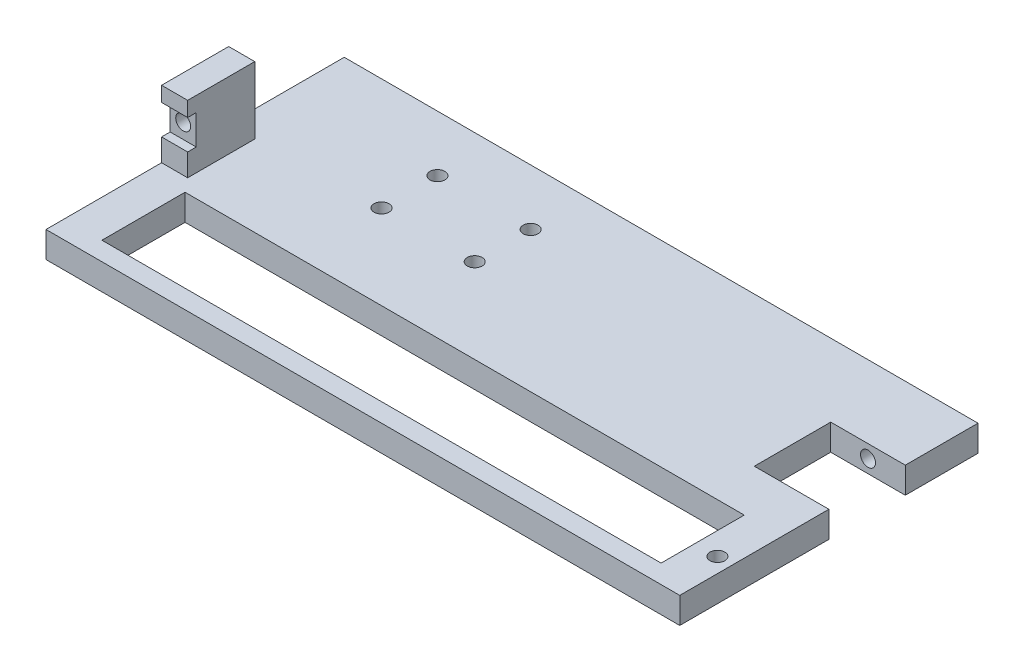
from build123d import *

# Parameters (mm, degrees)
SKETCH1_W           = 170
SKETCH1_H           = 80
BOSS_EXTRUDE1_DEPTH = 7
SKETCH2_W           = 7
SKETCH2_H           = 18
BOSS_EXTRUDE2_DEPTH = 18
SKETCH3_R           = 2
CUT_EXTRUDE1_DEPTH  = 20
SKETCH4_W           = 7
SKETCH4_H           = 8
CUT_EXTRUDE2_DEPTH  = 2.3
SKETCH5_W           = 150
SKETCH5_H           = 22.295371368
CUT_EXTRUDE3_DEPTH  = 11
SKETCH6_R           = 2
SKETCH6_W           = 20
SKETCH6_H           = 20.5
CUT_EXTRUDE4_DEPTH  = 11
SKETCH7_R           = 2
CUT_EXTRUDE5_DEPTH  = 25
CUT_EXTRUDE6_START  = 25
SKETCH7_2_R         = 2
CUT_EXTRUDE6_DEPTH  = 25
SKETCH10_R          = 2
CUT_EXTRUDE7_DEPTH  = 10


with BuildPart() as part:
    # Sketch1 → Boss-Extrude1 (new body)
    with BuildSketch(Plane(origin=(0, 0, 0), x_dir=(1, 0, 0), z_dir=(0, 1, 0))):
        with Locations((5.170316302, -0.291970803)):
            Rectangle(SKETCH1_W, SKETCH1_H)
    extrude(amount=BOSS_EXTRUDE1_DEPTH)

    # Sketch2 → Boss-Extrude2 (add)
    with BuildSketch(Plane(origin=(0, 7, 0), x_dir=(1, 0, 0), z_dir=(0, 1, 0))):
        with Locations((-76.329683698, -0.291970803)):
            Rectangle(SKETCH2_W, SKETCH2_H)
    extrude(amount=BOSS_EXTRUDE2_DEPTH)

    # Sketch3 → Cut-Extrude1 (cut)
    with BuildSketch(Plane(origin=(0, 0, -8.708029197), x_dir=(-1, 0, 0), z_dir=(0, 0, -1))):
        with Locations((76.329683698, 17)):
            Circle(SKETCH3_R)
    extrude(amount=-CUT_EXTRUDE1_DEPTH, mode=Mode.SUBTRACT)

    # Sketch4 → Cut-Extrude2 (cut)
    with BuildSketch(Plane.XY.offset(9.291970803)):
        with Locations((-76.329683698, 17)):
            Rectangle(SKETCH4_W, SKETCH4_H)
    extrude(amount=-CUT_EXTRUDE2_DEPTH, mode=Mode.SUBTRACT)

    # Sketch5 → Cut-Extrude3 (cut)
    with BuildSketch(Plane(origin=(0, 7, 0), x_dir=(1, 0, 0), z_dir=(0, 1, 0))):
        with Locations((5.170316302, -24.144285119)):
            Rectangle(SKETCH5_W, SKETCH5_H)
    extrude(amount=-CUT_EXTRUDE3_DEPTH, mode=Mode.SUBTRACT)

    # Sketch6 → Cut-Extrude4 (cut)
    with BuildSketch(Plane(origin=(0, 7, 0), x_dir=(1, 0, 0), z_dir=(0, 1, 0))):
        with Locations((86.170316302, -26.191970803)):
            Circle(SKETCH6_R)
        with Locations((80.170316302, 9.958029197)):
            Rectangle(SKETCH6_W, SKETCH6_H)
    extrude(amount=-CUT_EXTRUDE4_DEPTH, mode=Mode.SUBTRACT)

    # Sketch7 → Cut-Extrude5 (cut)
    with BuildSketch(Plane.XY.offset(-20.208029197)):
        with Locations((80.170316302, 3.5)):
            Circle(SKETCH7_R)
    extrude(amount=-CUT_EXTRUDE5_DEPTH, mode=Mode.SUBTRACT)

    # Sketch7_2 → Cut-Extrude6 (cut)
    with BuildSketch(Plane.XY.offset(-20.208029197).offset(CUT_EXTRUDE6_START)):
        with Locations((80.170316302, 3.5)):
            Circle(SKETCH7_2_R)
    extrude(amount=-CUT_EXTRUDE6_DEPTH, mode=Mode.SUBTRACT)

    # Sketch10 → Cut-Extrude7 (cut)
    with BuildSketch(Plane.XZ):
        with Locations((-39.829683698, -9.708029197)):
            Circle(SKETCH10_R)
        with Locations((-39.829683698, -24.708029197)):
            Circle(SKETCH10_R)
        with Locations((-14.829683698, -24.708029197)):
            Circle(SKETCH10_R)
        with Locations((-14.829683698, -9.708029197)):
            Circle(SKETCH10_R)
    extrude(amount=-CUT_EXTRUDE7_DEPTH, mode=Mode.SUBTRACT)


solid = part.part
